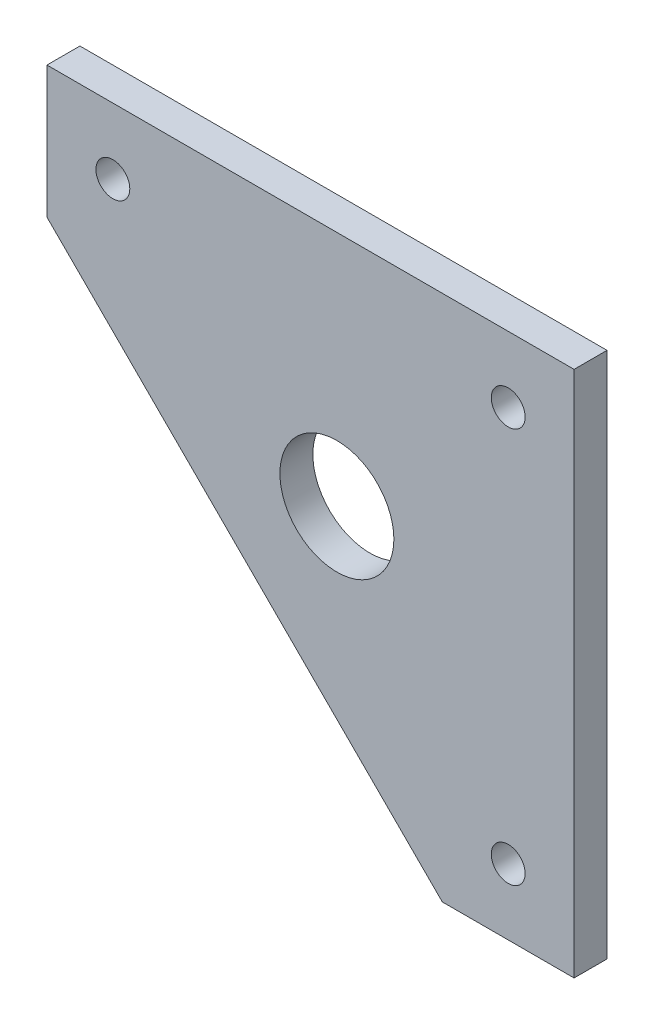
from build123d import *

# Parameters (mm, degrees)
SKETCH1_R               = 10.9855
BOSS_EXTRUDE1_DEPTH     = 6.35
F_1_4_CLEARANCE_HOLE1_D = 6.5278


with BuildPart() as part:
    # Sketch1 → Boss-Extrude1 (new body)
    with BuildSketch(Plane.XY):
        Polygon((-88.9, 12.7), (-88.9, -12.7), (-12.7, -88.9), (12.7, -88.9), (12.7, 12.7), align=None)
        with Locations((-33.02, -33.02)):
            Circle(SKETCH1_R, mode=Mode.SUBTRACT)
    extrude(amount=BOSS_EXTRUDE1_DEPTH)

    # 1/4 Clearance Hole1 (through all)
    with Locations(Plane.XY.offset(6.35)):
        with Locations((0, 0), (-76.2, 0), (0, -76.2)):
            Hole(F_1_4_CLEARANCE_HOLE1_D / 2)


solid = part.part
